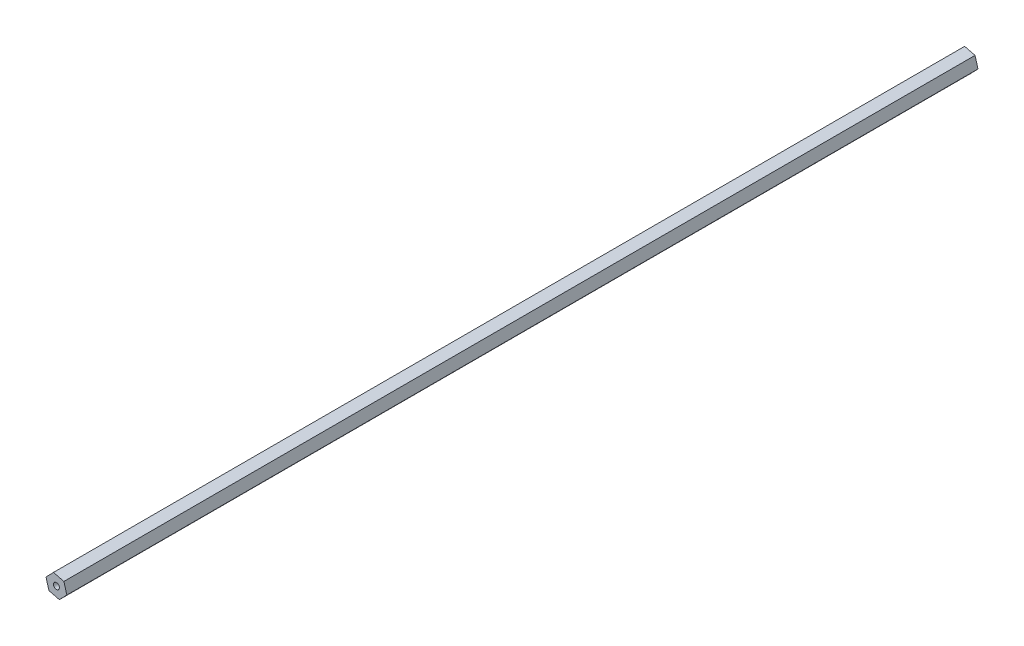
from build123d import *

# Parameters (mm, degrees)
BOSS_EXTRUDE1_DEPTH = 622.046
SKETCH2_R           = 2.032
CUT_EXTRUDE1_DEPTH  = 736.6


with BuildPart() as part:
    # Sketch1 → Boss-Extrude1 (new body)
    with BuildSketch(Plane.XY):
        Polygon((-7.113422827, 1.778355707), (-5.096812632, -5.271227023), (2.016610194, -7.049582729), (7.113422827, -1.778355707), (5.096812632, 5.271227023), (-2.016610194, 7.049582729), align=None)
    extrude(amount=BOSS_EXTRUDE1_DEPTH)

    # Sketch2 → Cut-Extrude1 (cut)
    with BuildSketch(Plane.XY.offset(622.046)):
        Circle(SKETCH2_R)
    extrude(amount=-CUT_EXTRUDE1_DEPTH, mode=Mode.SUBTRACT)


solid = part.part
